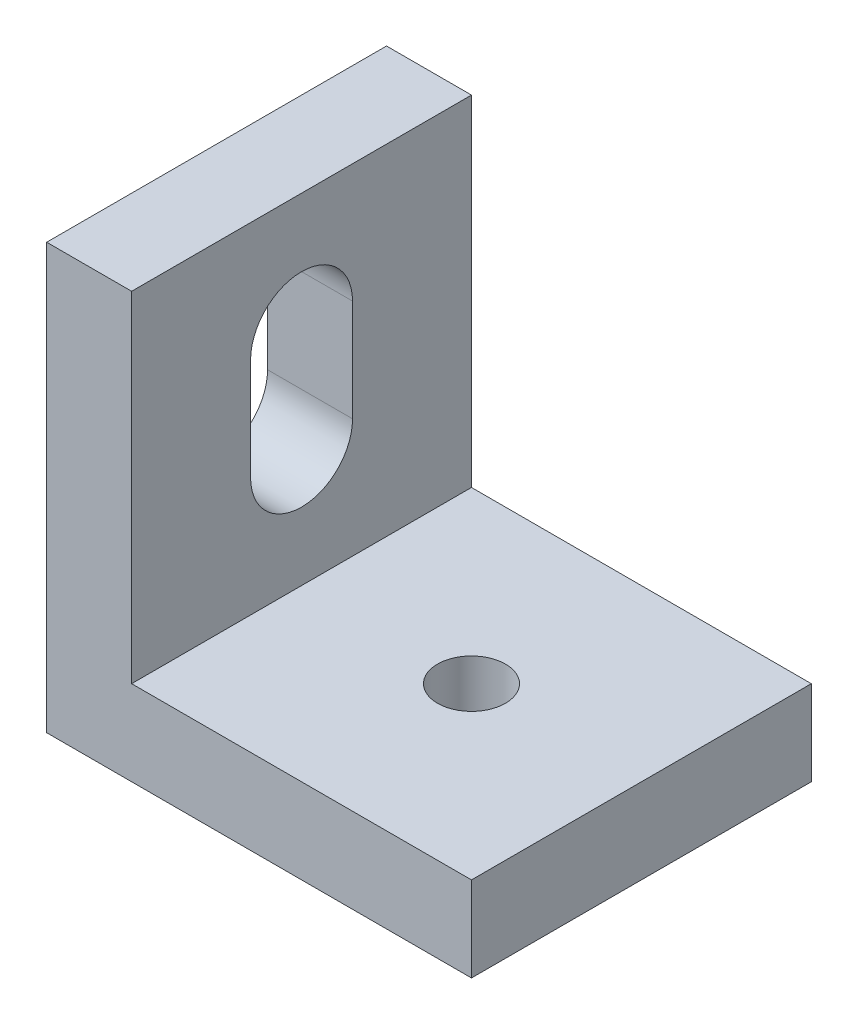
from build123d import *

# Parameters (mm, degrees)
SKETCH1_W           = 20
SKETCH1_H           = 20
SKETCH1_R           = 2
BOSS_EXTRUDE1_DEPTH = 5
SKETCH2_W           = 5
SKETCH2_H           = 20
BOSS_EXTRUDE2_DEPTH = 25
SKETCH3_W           = 6
SKETCH3_H           = 6
CUT_EXTRUDE1_DEPTH  = 25


with BuildPart() as part:
    # Sketch1 → Boss-Extrude1 (new body)
    with BuildSketch(Plane(origin=(0, 0, 0), x_dir=(1, 0, 0), z_dir=(0, 1, 0))):
        Rectangle(SKETCH1_W, SKETCH1_H)
        Circle(SKETCH1_R, mode=Mode.SUBTRACT)
    extrude(amount=BOSS_EXTRUDE1_DEPTH)

    # Sketch2 → Boss-Extrude2 (add)
    with BuildSketch(Plane.XZ):
        with Locations((-12.5, 0)):
            Rectangle(SKETCH2_W, SKETCH2_H)
    extrude(amount=-BOSS_EXTRUDE2_DEPTH)

    # Sketch3 → Cut-Extrude1 (cut)
    with BuildSketch(Plane(origin=(-10, 0, 0), x_dir=(0, 0, -1), z_dir=(1, 0, 0))):
        with BuildLine():
            ThreePointArc((-3, 18), (0, 21), (3, 18))
            Line((3, 18), (-3, 18))
        make_face()
        with Locations((0, 15)):
            Rectangle(SKETCH3_W, SKETCH3_H)
        with BuildLine():
            ThreePointArc((3, 12), (0, 9), (-3, 12))
            Line((-3, 12), (3, 12))
        make_face()
    extrude(amount=-CUT_EXTRUDE1_DEPTH, mode=Mode.SUBTRACT)


solid = part.part
